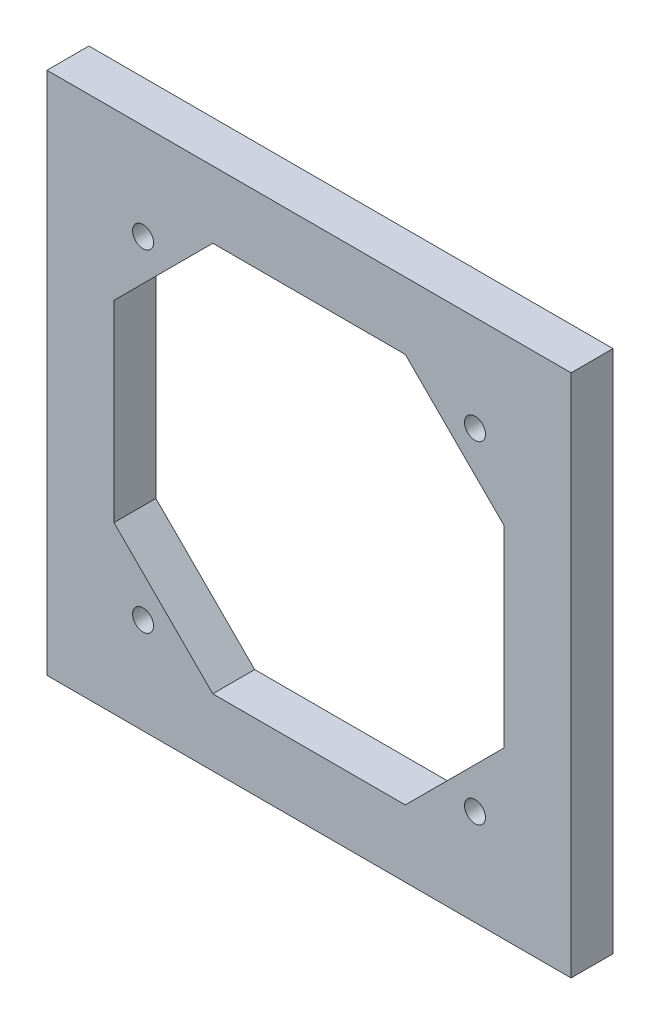
from build123d import *

# Parameters (mm, degrees)
SKETCH1_W           = 75
SKETCH1_H           = 75
SKETCH1_R           = 1.5
BOSS_EXTRUDE1_DEPTH = 6


with BuildPart() as part:
    # Sketch1 → Boss-Extrude1 (new body)
    with BuildSketch(Plane.XY):
        Rectangle(SKETCH1_W, SKETCH1_H)
        with Locations((-23.75, 23.75)):
            Circle(SKETCH1_R, mode=Mode.SUBTRACT)
        with Locations((23.75, 23.75)):
            Circle(SKETCH1_R, mode=Mode.SUBTRACT)
        with Locations((23.75, -23.75)):
            Circle(SKETCH1_R, mode=Mode.SUBTRACT)
        with Locations((-23.75, -23.75)):
            Circle(SKETCH1_R, mode=Mode.SUBTRACT)
        Polygon((-27.914213562, 13.772077939), (-13.772077939, 27.914213562), (13.772077939, 27.914213562), (27.914213562, 13.772077939), (27.914213562, -13.772077939), (13.772077939, -27.914213562), (-13.772077939, -27.914213562), (-27.914213562, -13.772077939), align=None, mode=Mode.SUBTRACT)
    extrude(amount=BOSS_EXTRUDE1_DEPTH)


solid = part.part
